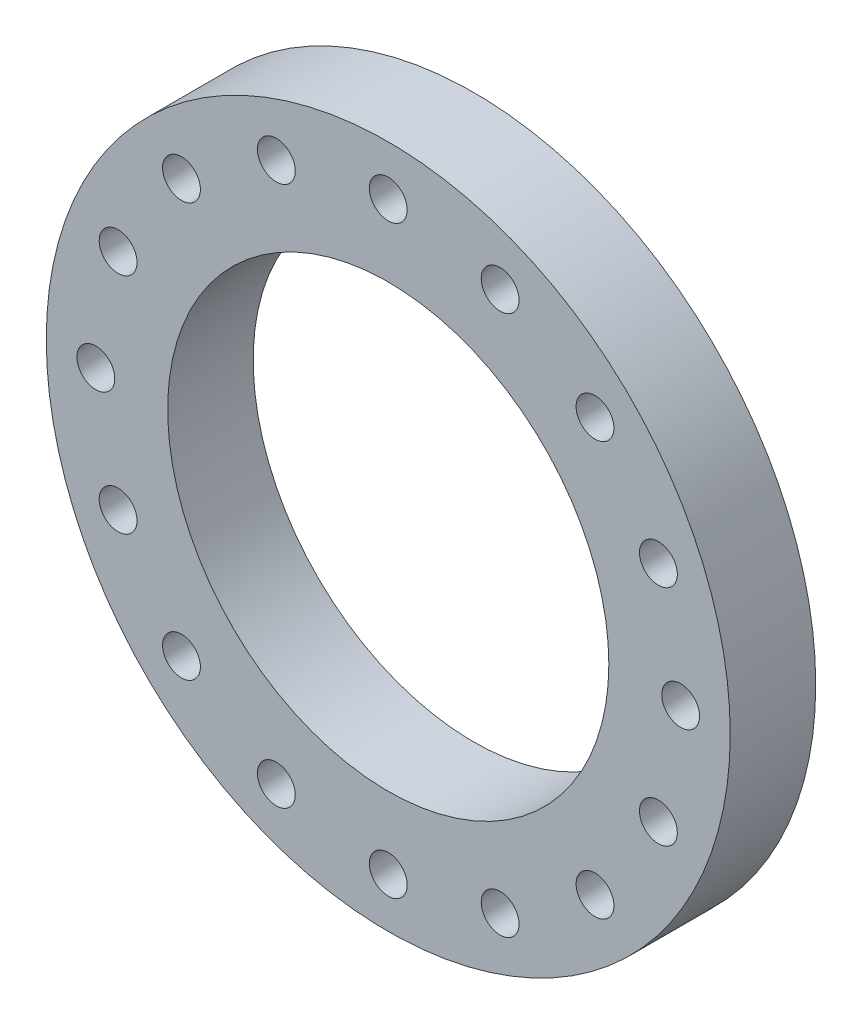
from build123d import *

# Parameters (mm, degrees)
SKETCH1_R           = 76.2
SKETCH1_R_2         = 49.149
EXTRUDE_THIN1_DEPTH = 19.05
SKETCH2_R           = 4.2164
CUT_EXTRUDE3_DEPTH  = 110.433918417
CIRPATTERN1_COUNT   = 16


with BuildPart() as part:
    # Sketch1 → Extrude-Thin1 (new body)
    with BuildSketch(Plane.XY):
        Circle(SKETCH1_R)
        Circle(SKETCH1_R_2, mode=Mode.SUBTRACT)
    extrude(amount=EXTRUDE_THIN1_DEPTH)

    # Sketch2 → Cut-Extrude3 (cut, through all)
    with BuildSketch(Plane.XY):
        with Locations((0, 65.151)):
            Circle(SKETCH2_R)
    cut_extrude3 = extrude(amount=CUT_EXTRUDE3_DEPTH, mode=Mode.SUBTRACT)

    # CirPattern1: Cut-Extrude3 ×16 about axis
    cirpattern1_axis = Axis((0, 0, 78.235991327), (0, 0, -1))
    for i in range(1, CIRPATTERN1_COUNT):
        add(cut_extrude3.rotate(cirpattern1_axis, i * 360 / CIRPATTERN1_COUNT), mode=Mode.SUBTRACT)


solid = part.part
